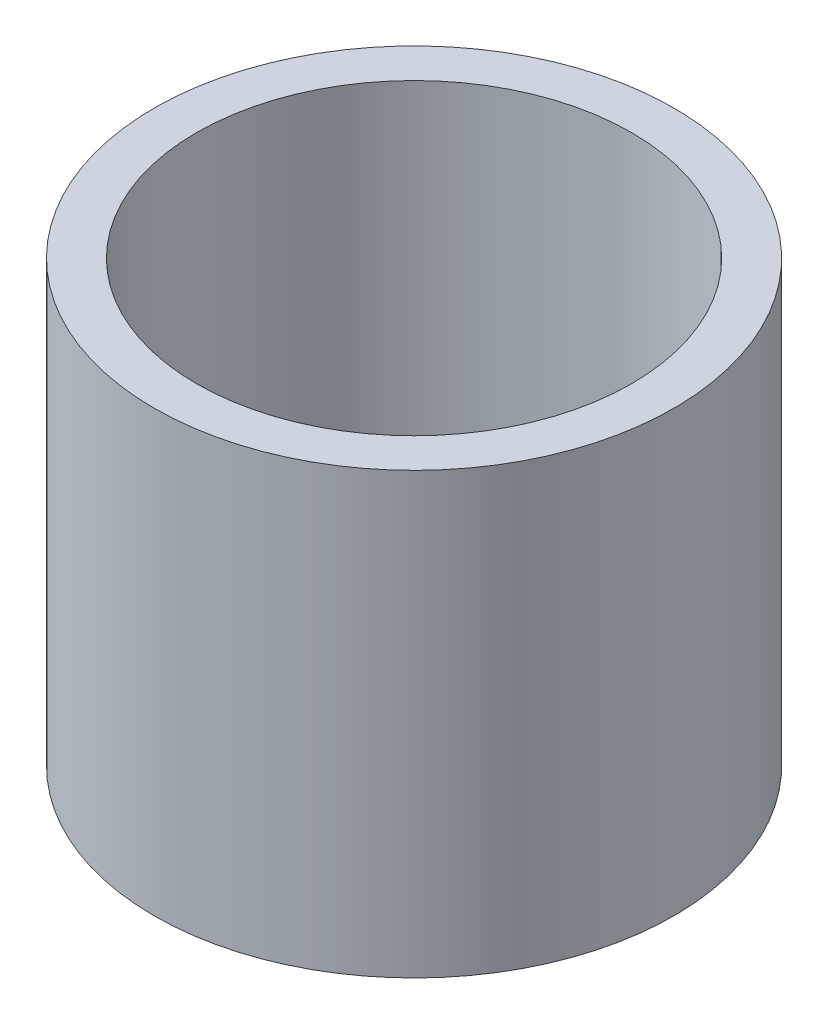
from build123d import *

# Parameters (mm, degrees)
SKETCH2_R           = 11.684
SKETCH2_R_2         = 9.652
SKETCH2_R_3         = 5.08
BOSS_EXTRUDE2_DEPTH = 1.9812
SKETCH4_R           = 11.684
SKETCH4_R_2         = 9.779
BOSS_EXTRUDE3_DEPTH = 17.78


with BuildPart() as part:
    # Sketch2 → Boss-Extrude2 (new body)
    with BuildSketch(Plane(origin=(0, 0, 0), x_dir=(1, 0, 0), z_dir=(0, 1, 0))):
        with Locations(Location((0, 0, 0), (0, 0, 270))):
            Circle(SKETCH2_R)
        with Locations((0, 0.290686297)):
            Circle(SKETCH2_R_2, mode=Mode.SUBTRACT)
        with Locations((0, 0.290686297)):
            Circle(SKETCH2_R_2)
        with Locations(Location((0, 0, 0), (0, 0, 270))):
            Circle(SKETCH2_R_3, mode=Mode.SUBTRACT)
    extrude(amount=BOSS_EXTRUDE2_DEPTH)

    # Sketch4 → Boss-Extrude3 (add)
    with BuildSketch(Plane(origin=(0, 1.9812, 0), x_dir=(1, 0, 0), z_dir=(0, 1, 0))):
        with Locations(Location((0, 0, 0), (0, 0, 270))):
            Circle(SKETCH4_R)
        with Locations(Location((0, 0, 0), (0, 0, 270))):
            Circle(SKETCH4_R_2, mode=Mode.SUBTRACT)
    extrude(amount=BOSS_EXTRUDE3_DEPTH)


solid = part.part
